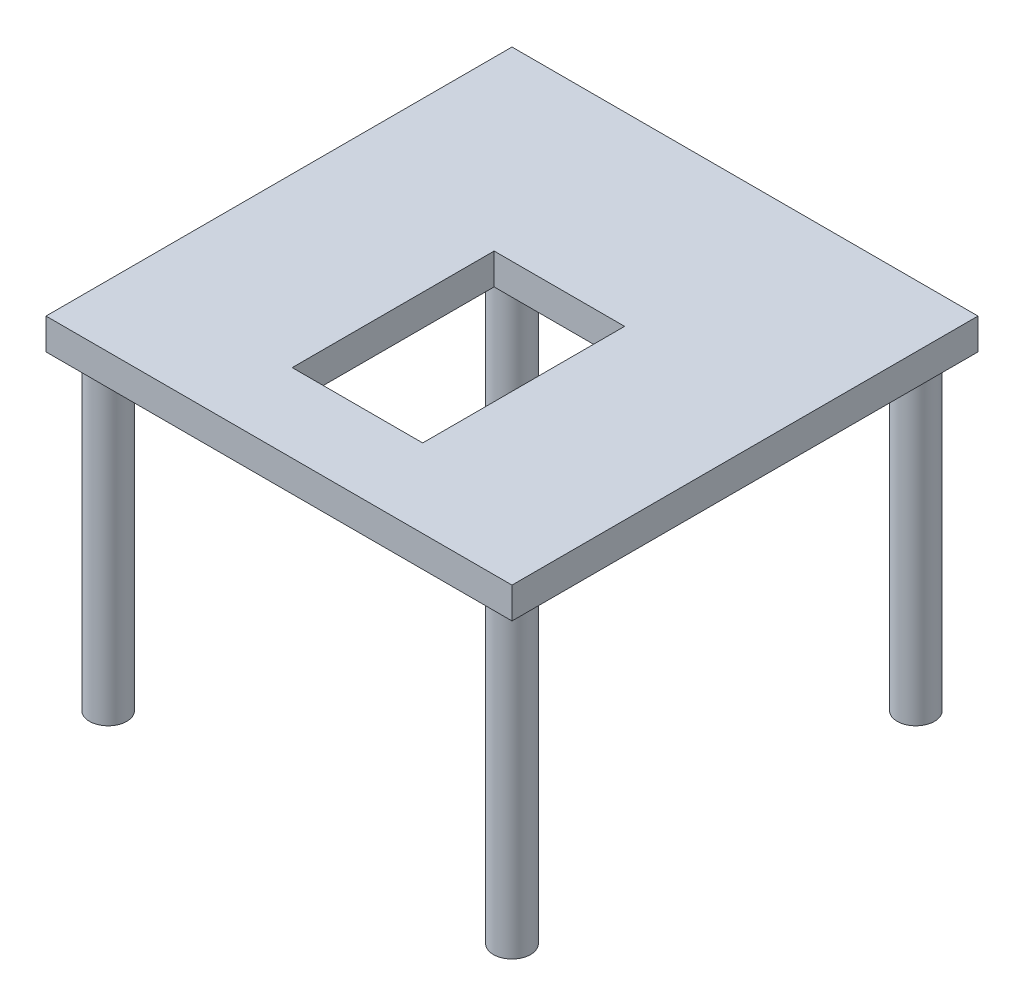
from build123d import *

# Parameters (mm, degrees)
SKETCH1_W           = 150
SKETCH1_H           = 150
BOSS_EXTRUDE2_DEPTH = 10
BOSS_EXTRUDE3_DEPTH = 100
SKETCH4_W           = 42
SKETCH4_H           = 65
CUT_EXTRUDE1_DEPTH  = 111


with BuildPart() as part:
    # Sketch1 → Boss-Extrude2 (new body)
    with BuildSketch(Plane(origin=(0, 0, 0), x_dir=(1, 0, 0), z_dir=(0, 1, 0))):
        Rectangle(SKETCH1_W, SKETCH1_H)
    extrude(amount=BOSS_EXTRUDE2_DEPTH)

    # Sketch3 → Boss-Extrude3 (add)
    with BuildSketch(Plane.XZ):
        with BuildLine():
            ThreePointArc((-59, 65), (-69.242640687, 69.242640687), (-65, 59))
            Line((-65, 59), (-65, 65))
            Line((-65, 65), (-59, 65))
        make_face()
        with BuildLine():
            Line((-65, 65), (-65, 59))
            ThreePointArc((-65, 59), (-60.757359313, 60.757359313), (-59, 65))
            Line((-59, 65), (-65, 65))
        make_face()
        with BuildLine():
            ThreePointArc((59, 65), (60.757359313, 60.757359313), (65, 59))
            Line((65, 59), (65, 65))
            Line((65, 65), (59, 65))
        make_face()
        with BuildLine():
            Line((65, 65), (65, 59))
            ThreePointArc((65, 59), (69.242640687, 60.757359313), (71, 65))
            ThreePointArc((71, 65), (65, 71), (59, 65))
            Line((59, 65), (65, 65))
        make_face()
        with BuildLine():
            ThreePointArc((59, 65), (60.757359313, 60.757359313), (65, 59))
            Line((65, 59), (65, 65))
            Line((65, 65), (59, 65))
        make_face()
        with BuildLine():
            Line((65, 65), (65, 59))
            ThreePointArc((65, 59), (69.242640687, 60.757359313), (71, 65))
            ThreePointArc((71, 65), (65, 71), (59, 65))
            Line((59, 65), (65, 65))
        make_face()
        with BuildLine():
            ThreePointArc((-59, 65), (-69.242640687, 69.242640687), (-65, 59))
            Line((-65, 59), (-65, 65))
            Line((-65, 65), (-59, 65))
        make_face()
        with BuildLine():
            Line((-65, 65), (-65, 59))
            ThreePointArc((-65, 59), (-60.757359313, 60.757359313), (-59, 65))
            Line((-59, 65), (-65, 65))
        make_face()
        with BuildLine():
            Line((-65, -59), (-65, -65))
            Line((-65, -65), (-59, -65))
            ThreePointArc((-59, -65), (-60.757359313, -60.757359313), (-65, -59))
        make_face()
        with BuildLine():
            Line((-59, -65), (-65, -65))
            Line((-65, -65), (-65, -59))
            ThreePointArc((-65, -59), (-69.242640687, -69.242640687), (-59, -65))
        make_face()
        with BuildLine():
            Line((-65, -59), (-65, -65))
            Line((-65, -65), (-59, -65))
            ThreePointArc((-59, -65), (-60.757359313, -60.757359313), (-65, -59))
        make_face()
        with BuildLine():
            Line((-59, -65), (-65, -65))
            Line((-65, -65), (-65, -59))
            ThreePointArc((-65, -59), (-69.242640687, -69.242640687), (-59, -65))
        make_face()
        with BuildLine():
            ThreePointArc((65, -59), (60.757359313, -60.757359313), (59, -65))
            Line((59, -65), (65, -65))
            Line((65, -65), (65, -59))
        make_face()
        with BuildLine():
            Line((65, -65), (59, -65))
            ThreePointArc((59, -65), (65, -71), (71, -65))
            ThreePointArc((71, -65), (69.242640687, -60.757359313), (65, -59))
            Line((65, -59), (65, -65))
        make_face()
        with BuildLine():
            ThreePointArc((65, -59), (60.757359313, -60.757359313), (59, -65))
            Line((59, -65), (65, -65))
            Line((65, -65), (65, -59))
        make_face()
        with BuildLine():
            Line((65, -65), (59, -65))
            ThreePointArc((59, -65), (65, -71), (71, -65))
            ThreePointArc((71, -65), (69.242640687, -60.757359313), (65, -59))
            Line((65, -59), (65, -65))
        make_face()
    extrude(amount=BOSS_EXTRUDE3_DEPTH)

    # Sketch4 → Cut-Extrude1 (cut, through all)
    with BuildSketch(Plane(origin=(0, 10, 0), x_dir=(1, 0, 0), z_dir=(0, 1, 0))):
        with Locations((0, -17.25)):
            Rectangle(SKETCH4_W, SKETCH4_H)
    extrude(amount=-CUT_EXTRUDE1_DEPTH, mode=Mode.SUBTRACT)


solid = part.part
